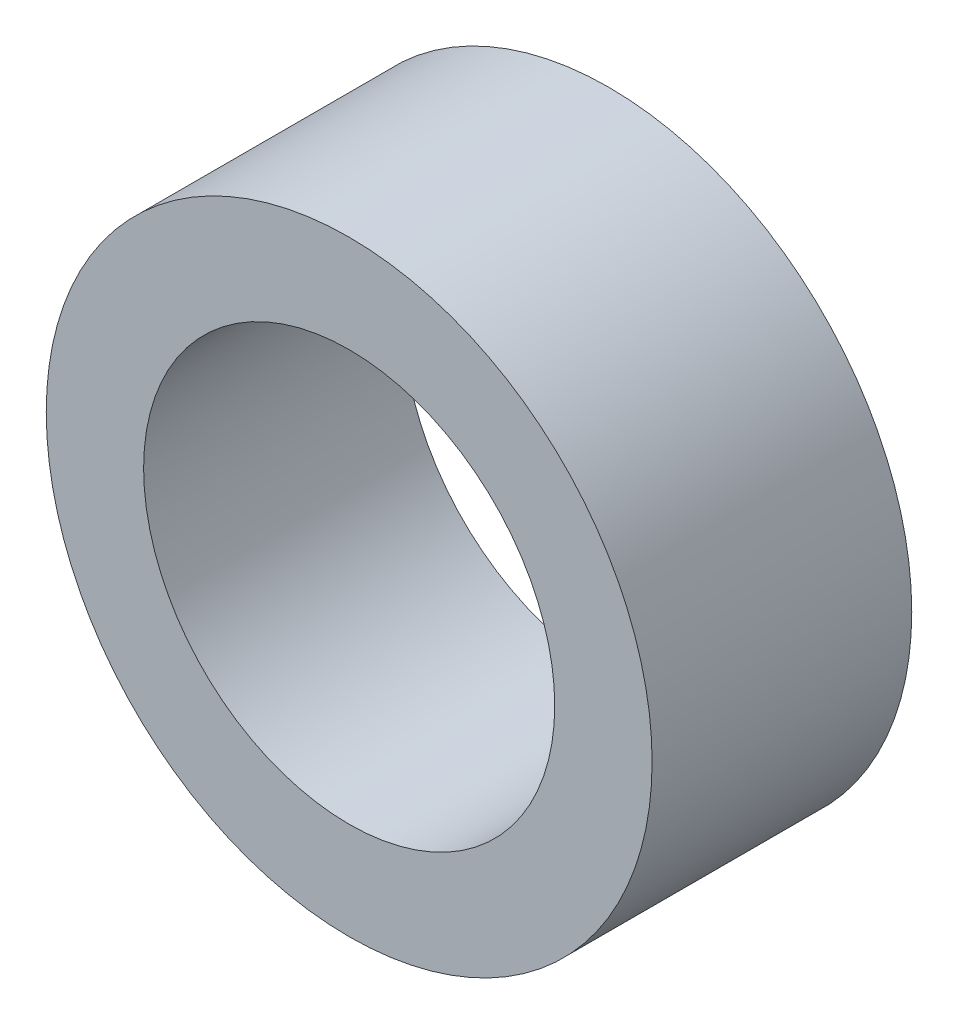
from build123d import *

# Parameters (mm, degrees)
SKETCH1_R           = 3.5
SKETCH1_R_2         = 2.375
BOSS_EXTRUDE1_DEPTH = 3


with BuildPart() as part:
    # Sketch1 → Boss-Extrude1 (new body)
    with BuildSketch(Plane.XY):
        Circle(SKETCH1_R)
        Circle(SKETCH1_R_2, mode=Mode.SUBTRACT)
    extrude(amount=BOSS_EXTRUDE1_DEPTH)


solid = part.part
